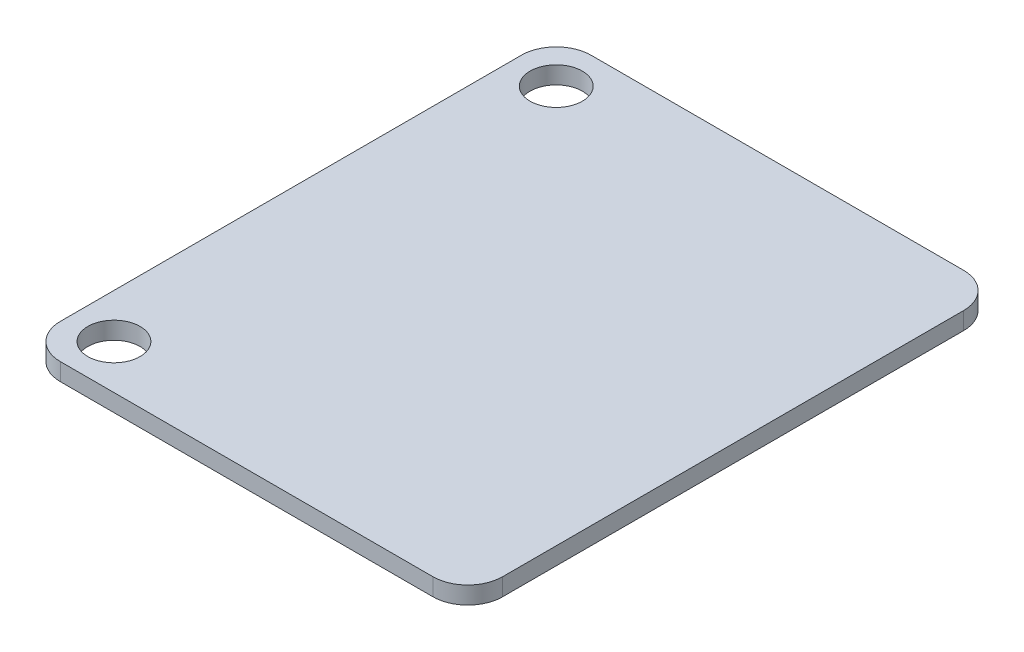
from build123d import *

# Parameters (mm, degrees)
SKETCH1_W           = 25.4
SKETCH1_H           = 30.48
SKETCH1_R           = 1.5
BOSS_EXTRUDE1_DEPTH = 1
FILLET1_R           = 2
FILLET2_R           = 2
FILLET3_R           = 2
FILLET4_R           = 2


with BuildPart() as part:
    # Sketch1 → Boss-Extrude1 (new body)
    with BuildSketch(Plane(origin=(0, 0, 0), x_dir=(1, 0, 0), z_dir=(0, 1, 0))):
        with Locations((0.180037034, 1.054001786)):
            Rectangle(SKETCH1_W, SKETCH1_H)
        with Locations((-9.979962966, 13.754001786)):
            Circle(SKETCH1_R, mode=Mode.SUBTRACT)
        with Locations((-9.979962966, -11.645998214)):
            Circle(SKETCH1_R, mode=Mode.SUBTRACT)
    extrude(amount=BOSS_EXTRUDE1_DEPTH)

    # Fillet1
    fillet1_edges = [part.edges().sort_by_distance(p)[0] for p in [
        (-12.519962966, 0.5, 14.185998214),
    ]]
    fillet(fillet1_edges, radius=FILLET1_R)

    # Fillet2
    fillet2_edges = [part.edges().sort_by_distance(p)[0] for p in [
        (12.880037034, 0.5, 14.185998214),
    ]]
    fillet(fillet2_edges, radius=FILLET2_R)

    # Fillet3
    fillet3_edges = [part.edges().sort_by_distance(p)[0] for p in [
        (12.880037034, 0.5, -16.294001786),
    ]]
    fillet(fillet3_edges, radius=FILLET3_R)

    # Fillet4
    fillet4_edges = [part.edges().sort_by_distance(p)[0] for p in [
        (-12.519962966, 0.5, -16.294001786),
    ]]
    fillet(fillet4_edges, radius=FILLET4_R)


solid = part.part
